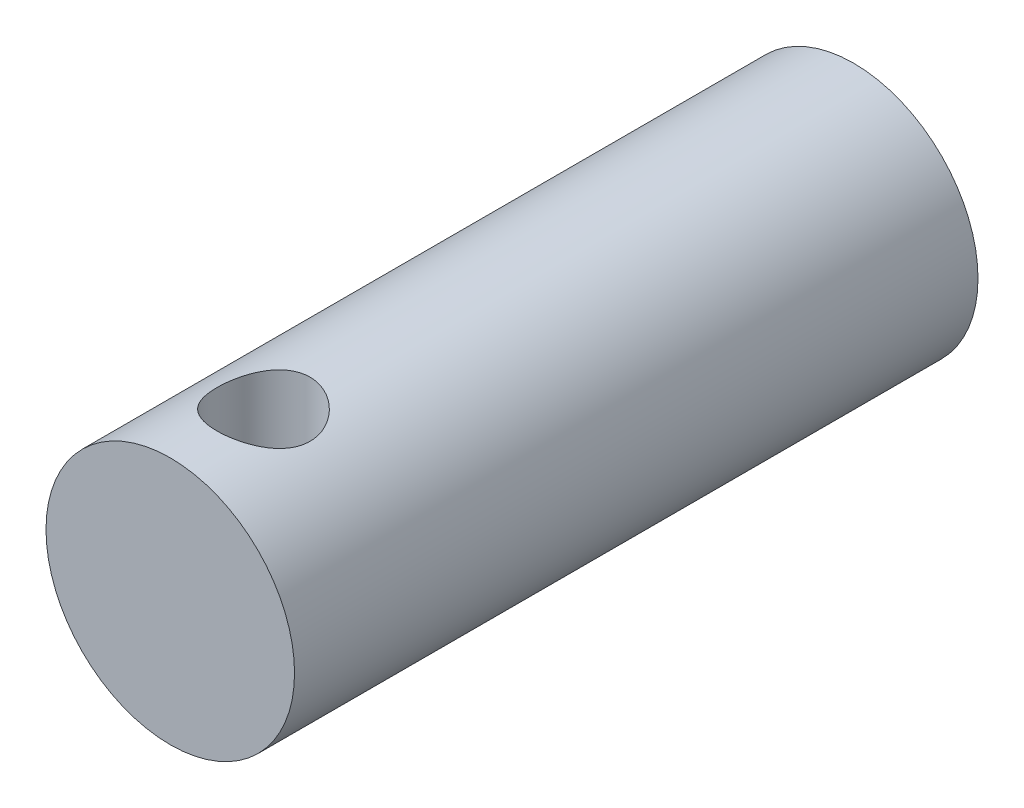
from build123d import *

# Parameters (mm, degrees)
SKETCH1_R           = 4
BOSS_EXTRUDE1_DEPTH = 22
SKETCH2_R           = 1.5
CUT_EXTRUDE1_DEPTH  = 9


with BuildPart() as part:
    # Sketch1 → Boss-Extrude1 (new body)
    with BuildSketch(Plane.XY):
        Circle(SKETCH1_R)
    extrude(amount=BOSS_EXTRUDE1_DEPTH)

    # Sketch2 → Cut-Extrude1 (cut, through all)
    with BuildSketch(Plane(origin=(0, 4, 0), x_dir=(1, 0, 0), z_dir=(0, 1, 0))):
        with Locations((0, -19)):
            Circle(SKETCH2_R)
    extrude(amount=-CUT_EXTRUDE1_DEPTH, mode=Mode.SUBTRACT)


solid = part.part
